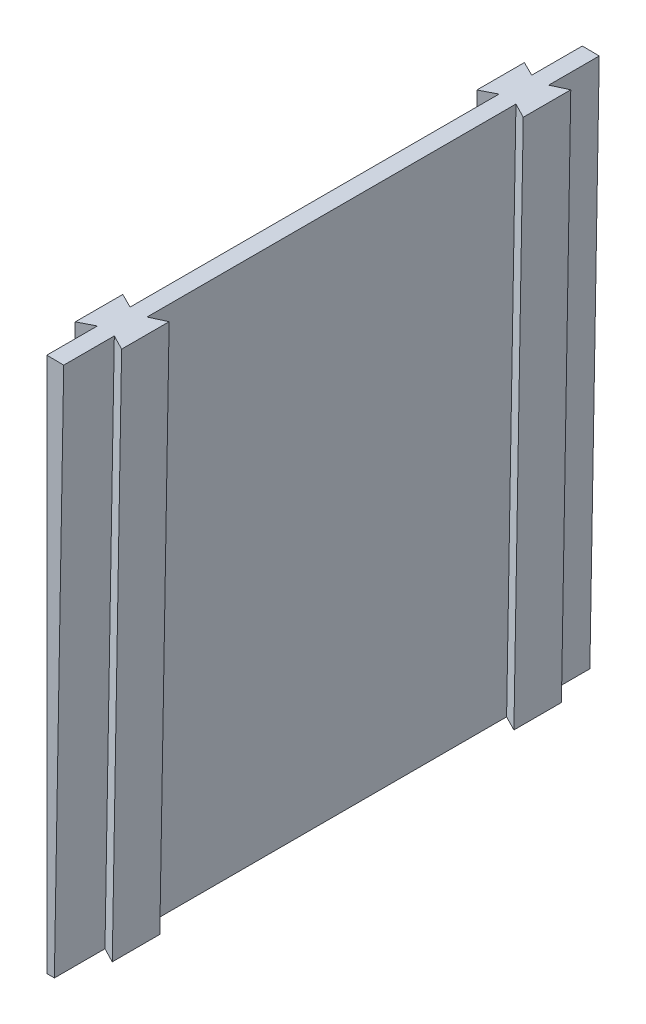
from build123d import *

# Parameters (mm, degrees)
BOSS_EXTRUDE1_DEPTH      = 101.6
BOSS_EXTRUDE2_REACH      = 145.704
BOSS_EXTRUDE2_END_RADIUS = 184.15
BOSS_EXTRUDE3_REACH      = 145.81
BOSS_EXTRUDE3_END_RADIUS = 184.15


with BuildPart() as part:
    # Sketch1 → Boss-Extrude1 (new body)
    with BuildSketch(Plane.XY):
        with BuildLine():
            Line((0, 82.55), (0, 184.15))
            ThreePointArc((0, 184.15), (1.606991512, 184.142988132), (3.213860645, 184.121953063))
            Line((3.213860645, 184.121953063), (1.440696151, 82.537427235))
            ThreePointArc((1.440696151, 82.537427235), (0.720375505, 82.546856749), (0, 82.55))
        make_face()
    extrude(amount=BOSS_EXTRUDE1_DEPTH)

    # Boss-Extrude2: up to this cylinder (the profile starts inside it)
    boss_extrude2_end = Plane(origin=(0, 0, 50.8), z_dir=(0, 0, -1)) * Cylinder(BOSS_EXTRUDE2_END_RADIUS, 736.908, mode=Mode.PRIVATE)
    # Sketch2 → Boss-Extrude2 (add, up to the surface)
    with BuildSketch(Plane(origin=(1.440696151, 82.537427235, 0), x_dir=(0, 0, -1), z_dir=(-0.017452406437283546, -0.9998476951563914, 0)), mode=Mode.PRIVATE) as boss_extrude2_sk1:
        Polygon((-92.000208065, 0), (-93.4085, 2.794), (-84.3915, 2.794), (-85.799791935, 0), align=None)
    boss_extrude2_tool1 = extrude(boss_extrude2_sk1.sketch, amount=-BOSS_EXTRUDE2_REACH, mode=Mode.PRIVATE) & boss_extrude2_end
    add(boss_extrude2_tool1.solids().sort_by_distance((2.92366, 82.511542, 88.9))[0])
    # Sketch2 → Boss-Extrude2 (add, up to the surface)
    with BuildSketch(Plane(origin=(1.440696151, 82.537427235, 0), x_dir=(0, 0, -1), z_dir=(-0.017452406437283546, -0.9998476951563914, 0)), mode=Mode.PRIVATE) as boss_extrude2_sk2:
        Polygon((-15.800208065, 0), (-9.599791935, 0), (-8.1915, 2.794), (-17.2085, 2.794), align=None)
    boss_extrude2_tool2 = extrude(boss_extrude2_sk2.sketch, amount=-BOSS_EXTRUDE2_REACH, mode=Mode.PRIVATE) & boss_extrude2_end
    add(boss_extrude2_tool2.solids().sort_by_distance((2.92366, 82.511542, 12.7))[0])

    # Boss-Extrude3: up to this cylinder (the profile starts inside it)
    boss_extrude3_end = Plane(origin=(0, 0, 50.8), z_dir=(0, 0, -1)) * Cylinder(BOSS_EXTRUDE3_END_RADIUS, 737.12, mode=Mode.PRIVATE)
    # Sketch3 → Boss-Extrude3 (add, up to the surface)
    with BuildSketch(Plane(origin=(0, 82.55, 0), x_dir=(0, 0, -1), z_dir=(0, -1, 0)), mode=Mode.PRIVATE) as boss_extrude3_sk1:
        Polygon((-92.000208065, 0), (-93.4085, -2.79357446), (-84.3915, -2.79357446), (-85.799791935, 0), align=None)
    boss_extrude3_tool1 = extrude(boss_extrude3_sk1.sketch, amount=-BOSS_EXTRUDE3_REACH, mode=Mode.PRIVATE) & boss_extrude3_end
    add(boss_extrude3_tool1.solids().sort_by_distance((-1.482964, 82.55, 88.9))[0])
    # Sketch3 → Boss-Extrude3 (add, up to the surface)
    with BuildSketch(Plane(origin=(0, 82.55, 0), x_dir=(0, 0, -1), z_dir=(0, -1, 0)), mode=Mode.PRIVATE) as boss_extrude3_sk2:
        Polygon((-15.800208065, 0), (-9.599791935, 0), (-8.1915, -2.79357446), (-17.2085, -2.79357446), align=None)
    boss_extrude3_tool2 = extrude(boss_extrude3_sk2.sketch, amount=-BOSS_EXTRUDE3_REACH, mode=Mode.PRIVATE) & boss_extrude3_end
    add(boss_extrude3_tool2.solids().sort_by_distance((-1.482964, 82.55, 12.7))[0])


solid = part.part
